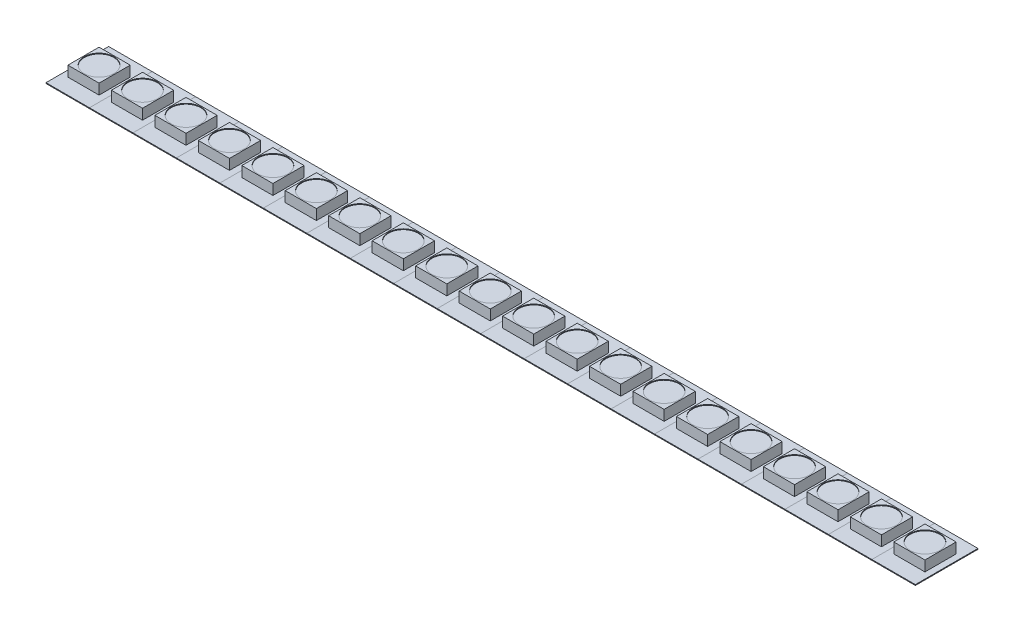
from build123d import *

# Parameters (mm, degrees)
SKETCH1_W           = 6.9088
SKETCH1_H           = 9.9568
BOSS_EXTRUDE1_DEPTH = 0.127
SKETCH3_W           = 4.953
SKETCH3_H           = 4.953
BOSS_EXTRUDE3_DEPTH = 1.651
SKETCH5_R           = 2.348345572
CUT_EXTRUDE1_DEPTH  = 0.127
LPATTERN1_COUNT     = 20
LPATTERN1_PITCH     = 6.9088


with BuildPart() as part:
    # Sketch1 → Boss-Extrude1 (new body)
    with BuildSketch(Plane(origin=(0, 0, 0), x_dir=(1, 0, 0), z_dir=(0, 1, 0))):
        Rectangle(SKETCH1_W, SKETCH1_H)
    extrude(amount=BOSS_EXTRUDE1_DEPTH)

    # Sketch3 → Boss-Extrude3 (add)
    with BuildSketch(Plane(origin=(0, 0.127, 0), x_dir=(1, 0, 0), z_dir=(0, 1, 0))):
        Rectangle(SKETCH3_W, SKETCH3_H)
    extrude(amount=BOSS_EXTRUDE3_DEPTH)

    # Sketch5 → Cut-Extrude1 (cut)
    with BuildSketch(Plane(origin=(0, 1.778, 0), x_dir=(1, 0, 0), z_dir=(0, 1, 0))):
        Circle(SKETCH5_R)
    extrude(amount=-CUT_EXTRUDE1_DEPTH, mode=Mode.SUBTRACT)


with BuildPart() as lpattern1_1:
    # LPattern1: pattern copy
    add(part.part.moved(Location(Vector(1, 0, 0) * (1 * LPATTERN1_PITCH))))


with BuildPart() as lpattern1_2:
    # LPattern1: pattern copy
    add(part.part.moved(Location(Vector(1, 0, 0) * (2 * LPATTERN1_PITCH))))


with BuildPart() as lpattern1_3:
    # LPattern1: pattern copy
    add(part.part.moved(Location(Vector(1, 0, 0) * (3 * LPATTERN1_PITCH))))


with BuildPart() as lpattern1_4:
    # LPattern1: pattern copy
    add(part.part.moved(Location(Vector(1, 0, 0) * (4 * LPATTERN1_PITCH))))


with BuildPart() as lpattern1_5:
    # LPattern1: pattern copy
    add(part.part.moved(Location(Vector(1, 0, 0) * (5 * LPATTERN1_PITCH))))


with BuildPart() as lpattern1_6:
    # LPattern1: pattern copy
    add(part.part.moved(Location(Vector(1, 0, 0) * (6 * LPATTERN1_PITCH))))


with BuildPart() as lpattern1_7:
    # LPattern1: pattern copy
    add(part.part.moved(Location(Vector(1, 0, 0) * (7 * LPATTERN1_PITCH))))


with BuildPart() as lpattern1_8:
    # LPattern1: pattern copy
    add(part.part.moved(Location(Vector(1, 0, 0) * (8 * LPATTERN1_PITCH))))


with BuildPart() as lpattern1_9:
    # LPattern1: pattern copy
    add(part.part.moved(Location(Vector(1, 0, 0) * (9 * LPATTERN1_PITCH))))


with BuildPart() as lpattern1_10:
    # LPattern1: pattern copy
    add(part.part.moved(Location(Vector(1, 0, 0) * (10 * LPATTERN1_PITCH))))


with BuildPart() as lpattern1_11:
    # LPattern1: pattern copy
    add(part.part.moved(Location(Vector(1, 0, 0) * (11 * LPATTERN1_PITCH))))


with BuildPart() as lpattern1_12:
    # LPattern1: pattern copy
    add(part.part.moved(Location(Vector(1, 0, 0) * (12 * LPATTERN1_PITCH))))


with BuildPart() as lpattern1_13:
    # LPattern1: pattern copy
    add(part.part.moved(Location(Vector(1, 0, 0) * (13 * LPATTERN1_PITCH))))


with BuildPart() as lpattern1_14:
    # LPattern1: pattern copy
    add(part.part.moved(Location(Vector(1, 0, 0) * (14 * LPATTERN1_PITCH))))


with BuildPart() as lpattern1_15:
    # LPattern1: pattern copy
    add(part.part.moved(Location(Vector(1, 0, 0) * (15 * LPATTERN1_PITCH))))


with BuildPart() as lpattern1_16:
    # LPattern1: pattern copy
    add(part.part.moved(Location(Vector(1, 0, 0) * (16 * LPATTERN1_PITCH))))


with BuildPart() as lpattern1_17:
    # LPattern1: pattern copy
    add(part.part.moved(Location(Vector(1, 0, 0) * (17 * LPATTERN1_PITCH))))


with BuildPart() as lpattern1_18:
    # LPattern1: pattern copy
    add(part.part.moved(Location(Vector(1, 0, 0) * (18 * LPATTERN1_PITCH))))


with BuildPart() as lpattern1_19:
    # LPattern1: pattern copy
    add(part.part.moved(Location(Vector(1, 0, 0) * (19 * LPATTERN1_PITCH))))


solid = Compound([part.part, lpattern1_1.part, lpattern1_2.part, lpattern1_3.part, lpattern1_4.part, lpattern1_5.part, lpattern1_6.part, lpattern1_7.part, lpattern1_8.part, lpattern1_9.part, lpattern1_10.part, lpattern1_11.part, lpattern1_12.part, lpattern1_13.part, lpattern1_14.part, lpattern1_15.part, lpattern1_16.part, lpattern1_17.part, lpattern1_18.part, lpattern1_19.part])
